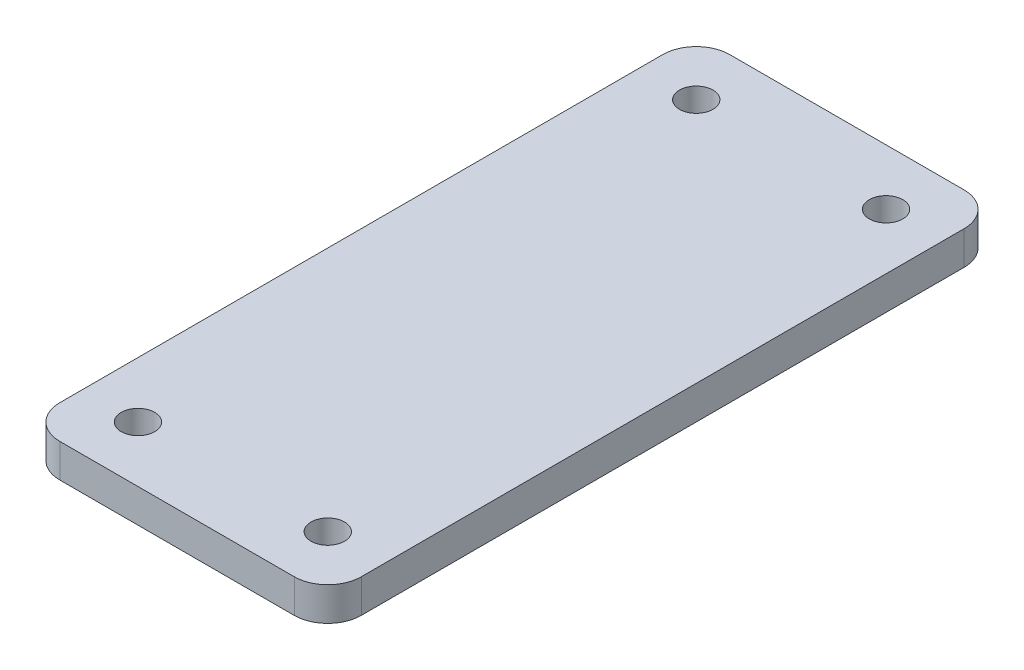
from build123d import *

# Parameters (mm, degrees)
SKETCH3_W           = 27
SKETCH3_H           = 60
BOSS_EXTRUDE1_DEPTH = 3
SKETCH4_R           = 1.5
CUT_EXTRUDE1_DEPTH  = 3
FILLET2_R           = 3
FILLET3_R           = 3


with BuildPart() as part:
    # Sketch3 → Boss-Extrude1 (new body)
    with BuildSketch(Plane(origin=(0, 0, 0), x_dir=(1, 0, 0), z_dir=(0, 1, 0))):
        Rectangle(SKETCH3_W, SKETCH3_H)
    extrude(amount=BOSS_EXTRUDE1_DEPTH)

    # Sketch4 → Cut-Extrude1 (cut)
    with BuildSketch(Plane(origin=(0, 3, 0), x_dir=(1, 0, 0), z_dir=(0, 1, 0))):
        with Locations((-8.5, 25)):
            Circle(SKETCH4_R)
        with Locations((8.5, 25)):
            Circle(SKETCH4_R)
        with Locations((8.5, -25)):
            Circle(SKETCH4_R)
        with Locations((-8.5, -25)):
            Circle(SKETCH4_R)
    extrude(amount=-CUT_EXTRUDE1_DEPTH, mode=Mode.SUBTRACT)

    # Fillet2
    fillet2_edges = [part.edges().sort_by_distance(p)[0] for p in [
        (-13.5, 1.5, 30),
    ]]
    fillet(fillet2_edges, radius=FILLET2_R)

    # Fillet3
    fillet3_edges = [part.edges().sort_by_distance(p)[0] for p in [
        (-13.5, 1.5, -30),
        (13.5, 1.5, -30),
        (13.5, 1.5, 30),
    ]]
    fillet(fillet3_edges, radius=FILLET3_R)


solid = part.part
